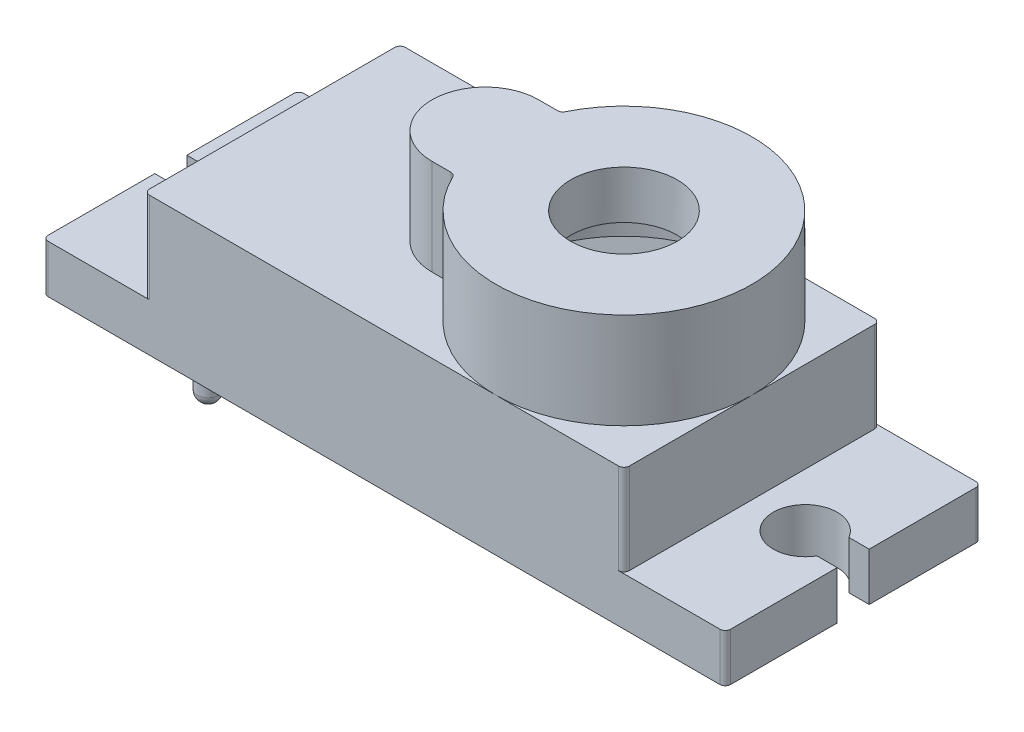
from build123d import *

# Parameters (mm, degrees)
SKETCH1_W            = 22.5
SKETCH1_H            = 12
BOSS_EXTRUDE1_DEPTH  = 6.5
SKETCH2_W            = 22.5
SKETCH2_H            = 12
BOSS_EXTRUDE2_DEPTH  = 0.5
BOSS_EXTRUDE3_DEPTH  = 4.5
SKETCH4_R            = 2.5
BOSS_EXTRUDE4_DEPTH  = 1
CUT_EXTRUDE1_DEPTH   = 7.5
SKETCH6_R            = 3
SKETCH6_R_2          = 2.5
BOSS_EXTRUDE5_DEPTH  = 1.25
BOSS_EXTRUDE7_DEPTH  = 2.25
BOSS_EXTRUDE8_DEPTH  = 1
SKETCH9_R            = 0.625
CUT_EXTRUDE2_DEPTH   = 0.25
SKETCH11_R           = 1.125
SKETCH11_R_2         = 0.5
BOSS_EXTRUDE9_DEPTH  = 6
SKETCH12_R           = 0.5
BOSS_EXTRUDE10_DEPTH = 2
FILLET1_R            = 0.5
FILLET2_R            = 0.25
CUT_EXTRUDE3_DEPTH   = 6


with BuildPart() as part:
    # Sketch1 → Boss-Extrude1 (new body)
    with BuildSketch(Plane(origin=(0, 0, 0), x_dir=(1, 0, 0), z_dir=(0, 1, 0))):
        Rectangle(SKETCH1_W, SKETCH1_H)
        Polygon((10.25, 5), (-10.25, 5), (-10.75, 5), (-10.75, -5), (-10.25, -5), (10.25, -5), (10.75, -5), (10.75, 5), align=None, mode=Mode.SUBTRACT)
    extrude(amount=BOSS_EXTRUDE1_DEPTH)

    # Sketch2 → Boss-Extrude2 (add)
    with BuildSketch(Plane(origin=(0, 6.5, 0), x_dir=(1, 0, 0), z_dir=(0, 1, 0))):
        Rectangle(SKETCH2_W, SKETCH2_H)
    extrude(amount=-BOSS_EXTRUDE2_DEPTH)

    # Sketch3 → Boss-Extrude3 (add)
    with BuildSketch(Plane(origin=(0, 6.5, 0), x_dir=(1, 0, 0), z_dir=(0, 1, 0))):
        with BuildLine():
            Line((-1.25, 2.5), (-0.204356057, 2.5))
            ThreePointArc((-0.204356057, 2.5), (11.25, 0), (-0.204356057, -2.5))
            Line((-0.204356057, -2.5), (-1.25, -2.5))
            ThreePointArc((-1.25, -2.5), (-3.75, 0), (-1.25, 2.5))
        make_face()
        with BuildLine():
            Line((-1.25, 2.1), (0.058661059, 2.1))
            ThreePointArc((0.058661059, 2.1), (10.85, 0), (0.058661059, -2.1))
            Line((0.058661059, -2.1), (-1.25, -2.1))
            ThreePointArc((-1.25, -2.1), (-3.35, 0), (-1.25, 2.1))
        make_face(mode=Mode.SUBTRACT)
    extrude(amount=BOSS_EXTRUDE3_DEPTH)

    # Sketch4 → Boss-Extrude4 (add)
    with BuildSketch(Plane(origin=(0, 11, 0), x_dir=(1, 0, 0), z_dir=(0, 1, 0))):
        with BuildLine():
            ThreePointArc((-1.25, -2.1), (-3.35, 0), (-1.25, 2.1))
            Line((-1.25, 2.1), (0.058661059, 2.1))
            ThreePointArc((0.058661059, 2.1), (10.85, 0), (0.058661059, -2.1))
            Line((0.058661059, -2.1), (-1.25, -2.1))
        make_face()
        with Locations((5.25, 0)):
            Circle(SKETCH4_R, mode=Mode.SUBTRACT)
    extrude(amount=-BOSS_EXTRUDE4_DEPTH)

    # Sketch5 → Cut-Extrude1 (cut, through all)
    with BuildSketch(Plane(origin=(0, 6.5, 0), x_dir=(1, 0, 0), z_dir=(0, 1, 0))):
        with BuildLine():
            Line((-1.25, -2.1), (0.058661059, -2.1))
            ThreePointArc((0.058661059, -2.1), (10.85, 0), (0.058661059, 2.1))
            Line((0.058661059, 2.1), (-1.25, 2.1))
            ThreePointArc((-1.25, 2.1), (-3.35, 0), (-1.25, -2.1))
        make_face()
    extrude(amount=-CUT_EXTRUDE1_DEPTH, mode=Mode.SUBTRACT)

    # Sketch6 → Boss-Extrude5 (add)
    with BuildSketch(Plane.XZ.offset(-10)):
        with Locations((5.25, 0)):
            Circle(SKETCH6_R)
        with Locations((5.25, 0)):
            Circle(SKETCH6_R_2, mode=Mode.SUBTRACT)
    extrude(amount=BOSS_EXTRUDE5_DEPTH)

    # Sketch7 → Boss-Extrude7 (add)
    with BuildSketch(Plane(origin=(0, 0, 0), x_dir=(1, 0, 0), z_dir=(0, 1, 0))):
        with BuildLine():
            Line((-11.25, -6), (-11.25, 6))
            Line((-11.25, 6), (-16, 6))
            Line((-16, 6), (-16, 0.75))
            Line((-16, 0.75), (-15.049038106, 0.75))
            ThreePointArc((-15.049038106, 0.75), (-12.25, 0), (-15.049038106, -0.75))
            Line((-15.049038106, -0.75), (-16, -0.75))
            Line((-16, -0.75), (-16, -6))
            Line((-16, -6), (-11.25, -6))
        make_face()
        with BuildLine():
            Line((-15, 1.430908802), (-15, 5))
            Line((-15, 5), (-11.5, 5))
            Line((-11.5, 5), (-11.5, -5))
            Line((-11.5, -5), (-15, -5))
            Line((-15, -5), (-15, -1.430908802))
            ThreePointArc((-15, -1.430908802), (-11.85, 0), (-15, 1.430908802))
        make_face(mode=Mode.SUBTRACT)
    boss_extrude7 = extrude(amount=BOSS_EXTRUDE7_DEPTH)

    # Sketch8 → Boss-Extrude8 (add)
    with BuildSketch(Plane(origin=(0, 2.25, 0), x_dir=(1, 0, 0), z_dir=(0, 1, 0))):
        with BuildLine():
            Line((-15.049038106, 0.75), (-16, 0.75))
            Line((-16, 0.75), (-16, 6))
            Line((-16, 6), (-11.25, 6))
            Line((-11.25, 6), (-11.25, -6))
            Line((-11.25, -6), (-16, -6))
            Line((-16, -6), (-16, -0.75))
            Line((-16, -0.75), (-15.049038106, -0.75))
            ThreePointArc((-15.049038106, -0.75), (-12.25, 0), (-15.049038106, 0.75))
        make_face()
    boss_extrude8 = extrude(amount=-BOSS_EXTRUDE8_DEPTH)

    # Mirror1: Boss-Extrude7, Boss-Extrude8 across plane
    add(boss_extrude7.mirror(Plane(origin=(0, 0, 0), x_dir=(0, 0, 1), z_dir=(1, 0, 0))))
    add(boss_extrude8.mirror(Plane(origin=(0, 0, 0), x_dir=(0, 0, 1), z_dir=(1, 0, 0))))

    # Sketch9 → Cut-Extrude2 (cut)
    with BuildSketch(Plane.XZ.offset(-10)):
        with Locations((-1.25, 0)):
            Circle(SKETCH9_R)
    extrude(amount=-CUT_EXTRUDE2_DEPTH, mode=Mode.SUBTRACT)

    # Sketch11 → Boss-Extrude9 (add)
    with BuildSketch(Plane.XZ.offset(-6)):
        with Locations((-9.75, 4.5)):
            Circle(SKETCH11_R)
        with Locations((-9.75, -4.5)):
            Circle(SKETCH11_R)
        with Locations((-9.75, -4.5)):
            Circle(SKETCH11_R_2, mode=Mode.SUBTRACT)
        with Locations((9.75, -4.5)):
            Circle(SKETCH11_R)
        with Locations((9.75, 4.5)):
            Circle(SKETCH11_R)
        with Locations((9.75, 4.5)):
            Circle(SKETCH11_R_2, mode=Mode.SUBTRACT)
    extrude(amount=BOSS_EXTRUDE9_DEPTH)

    # Sketch12 → Boss-Extrude10 (add)
    with BuildSketch(Plane.XZ):
        with Locations((-9.75, 4.5)):
            Circle(SKETCH12_R)
        with Locations((9.75, -4.5)):
            Circle(SKETCH12_R)
    extrude(amount=BOSS_EXTRUDE10_DEPTH)

    # Fillet1
    fillet1_edges = [part.edges().sort_by_distance(p)[0] for p in [
        (-10.25, -2, 4.5),
        (9.25, -2, -4.5),
    ]]
    fillet(fillet1_edges, radius=FILLET1_R)

    # Fillet2
    fillet2_edges = [part.edges().sort_by_distance(p)[0] for p in [
        (-16, 1.125, 6),
        (-16, 1.125, -6),
        (16, 1.125, -6),
        (16, 1.125, 6),
        (-0.204356057, 8.75, -2.5),
        (-0.204356057, 8.75, 2.5),
        (-11.25, 4.375, -6),
        (11.25, 4.375, -6),
        (11.25, 4.375, 6),
        (-11.25, 4.375, 6),
    ]]
    fillet(fillet2_edges, radius=FILLET2_R)

    # Sketch13 → Cut-Extrude3 (cut)
    with BuildSketch(Plane.XZ):
        with BuildLine():
            Line((0.058661059, 2.1), (0.058661059, -2.1))
            ThreePointArc((0.058661059, -2.1), (10.85, 0), (0.058661059, 2.1))
        make_face()
    extrude(amount=-CUT_EXTRUDE3_DEPTH, mode=Mode.SUBTRACT)


solid = part.part
